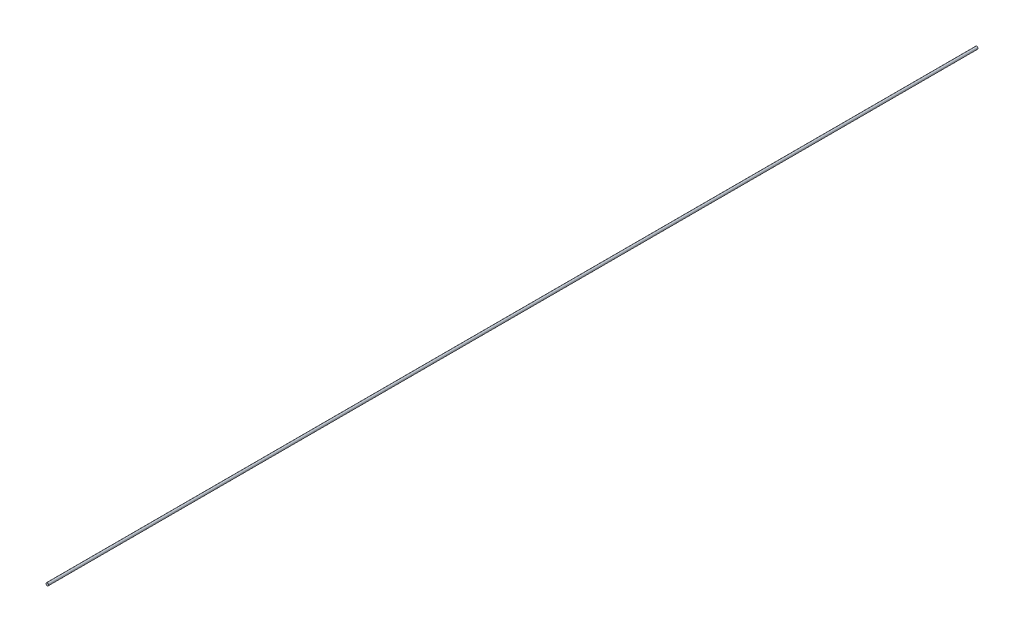
from build123d import *

# Parameters (mm, degrees)
ESQUISSE1_R        = 1.5
BOSS_EXTRU_1_DEPTH = 1088.1


with BuildPart() as part:
    # Esquisse1 → Boss.-Extru.1 (new body)
    with BuildSketch(Plane.XY):
        Circle(ESQUISSE1_R)
    extrude(amount=BOSS_EXTRU_1_DEPTH)


solid = part.part
